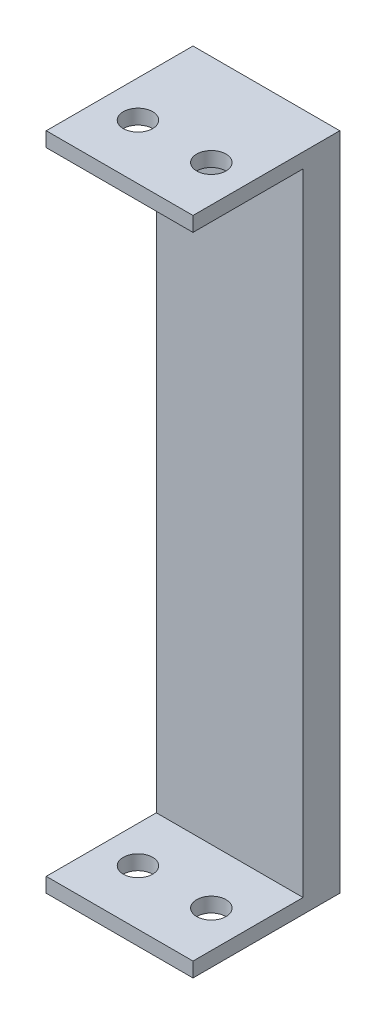
from build123d import *

# Parameters (mm, degrees)
SKETCH1_W               = 20
SKETCH1_H               = 90
BOSS_EXTRUDE1_DEPTH     = 20
CUT_EXTRUDE1_REACH      = 22
SKETCH2_W               = 15
SKETCH2_H               = 86
SKETCH3_R               = 2
CUT_EXTRUDE2_DEPTH      = 1
CUT_EXTRUDE2_DEPTH_BACK = 140


with BuildPart() as part:
    # Sketch1 → Boss-Extrude1 (new body)
    with BuildSketch(Plane.XY):
        Rectangle(SKETCH1_W, SKETCH1_H)
    extrude(amount=BOSS_EXTRUDE1_DEPTH)

    # Sketch2 → Cut-Extrude1 (cut, up to next)
    with BuildSketch(Plane(origin=(10, 0, 0), x_dir=(0, 0, -1), z_dir=(1, 0, 0)), mode=Mode.PRIVATE) as cut_extrude1_sk1:
        with Locations((-12.5, 0)):
            Rectangle(SKETCH2_W, SKETCH2_H)
    cut_extrude1_tool1 = extrude(cut_extrude1_sk1.sketch, amount=-CUT_EXTRUDE1_REACH, mode=Mode.PRIVATE) & part.part
    add(cut_extrude1_tool1.solids().sort_by_distance((10, 0, 12.5))[0], mode=Mode.SUBTRACT)

    # Sketch3 → Cut-Extrude2 (cut, two sides)
    with BuildSketch(Plane(origin=(0, 45, 0), x_dir=(1, 0, 0), z_dir=(0, 1, 0))) as cut_extrude2_sk:
        with Locations((-5, -12.5)):
            Circle(SKETCH3_R)
        with Locations((5, -12.5)):
            Circle(SKETCH3_R)
    extrude(amount=CUT_EXTRUDE2_DEPTH, mode=Mode.SUBTRACT)
    extrude(cut_extrude2_sk.sketch, amount=-CUT_EXTRUDE2_DEPTH_BACK, mode=Mode.SUBTRACT)


solid = part.part
